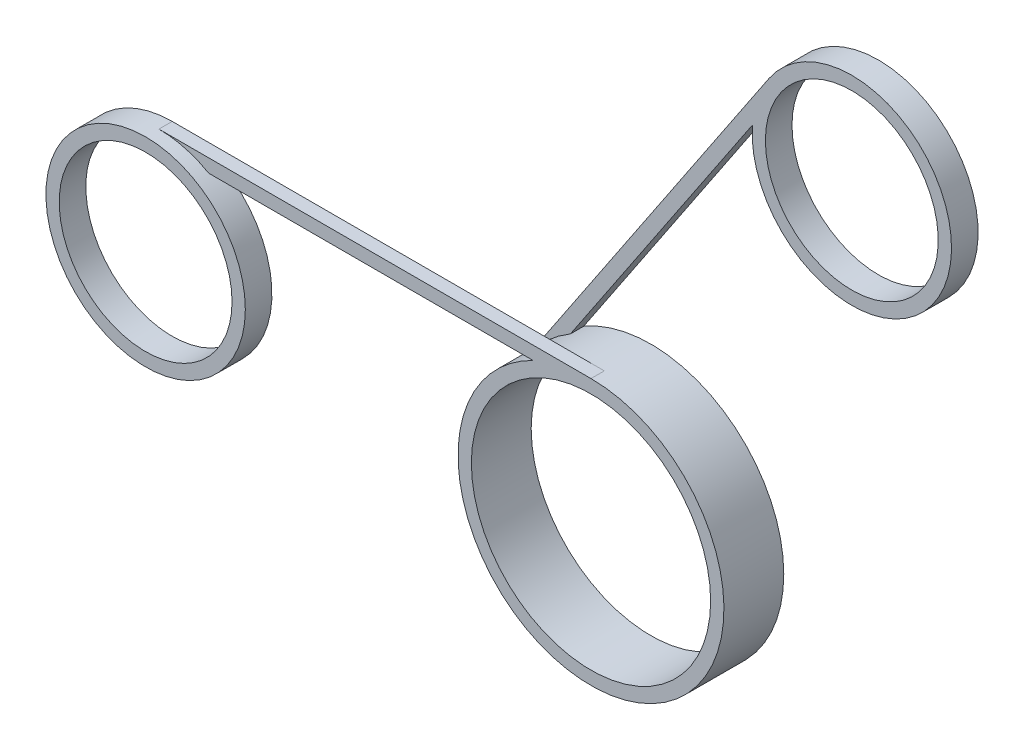
from build123d import *

# Parameters (mm, degrees)
SKETCH1_R           = 10
BOSS_EXTRUDE1_DEPTH = 4.5
SKETCH2_R           = 9
CUT_EXTRUDE1_DEPTH  = 4.5
SKETCH3_W           = 32.5
SKETCH3_H           = 1
BOSS_EXTRUDE2_DEPTH = 1
SKETCH5_R           = 7.5
BOSS_EXTRUDE3_DEPTH = 1
SKETCH6_R           = 6.5
CUT_EXTRUDE2_DEPTH  = 2
BOSS_EXTRUDE4_DEPTH = 1
SKETCH9_R           = 7.5
BOSS_EXTRUDE5_DEPTH = 1
SKETCH10_R          = 6.5
CUT_EXTRUDE3_DEPTH  = 2


with BuildPart() as part:
    # Sketch1 → Boss-Extrude1 (new body)
    with BuildSketch(Plane.XY):
        Circle(SKETCH1_R)
    extrude(amount=BOSS_EXTRUDE1_DEPTH)

    # Sketch2 → Cut-Extrude1 (cut)
    with BuildSketch(Plane.XY.offset(4.5)):
        Circle(SKETCH2_R)
    extrude(amount=-CUT_EXTRUDE1_DEPTH, mode=Mode.SUBTRACT)

    # Sketch3 → Boss-Extrude2 (add)
    with BuildSketch(Plane.XY.offset(4.5)):
        with Locations((-16.25, 9.5)):
            Rectangle(SKETCH3_W, SKETCH3_H)
    extrude(amount=-BOSS_EXTRUDE2_DEPTH)

    # Sketch5 → Boss-Extrude3 (add, symmetric)
    with BuildSketch(Plane.XY.offset(4.5)):
        with Locations((-32.5, 2.5)):
            Circle(SKETCH5_R)
    extrude(amount=BOSS_EXTRUDE3_DEPTH, both=True)

    # Sketch6 → Cut-Extrude2 (cut)
    with BuildSketch(Plane.XY.offset(5.5)):
        with Locations((-32.5, 2.5)):
            Circle(SKETCH6_R)
    extrude(amount=-CUT_EXTRUDE2_DEPTH, mode=Mode.SUBTRACT)

    # Sketch8 → Boss-Extrude4 (add)
    with BuildSketch(Plane(origin=(0, 0, 0), x_dir=(-1, 0, 0), z_dir=(0, 0, -1))):
        Polygon((8.194096935, 5.732082992), (-9.885510569, 32.739078243), (-10.716495038, 32.182782628), (7.362918515, 5.175657537), align=None)
    extrude(amount=-BOSS_EXTRUDE4_DEPTH)

    # Sketch9 → Boss-Extrude5 (add, symmetric)
    with BuildSketch(Plane(origin=(0, 0, 0), x_dir=(-1, 0, 0), z_dir=(0, 0, -1))):
        with Locations((-16.117894088, 28.566861127)):
            Circle(SKETCH9_R)
    extrude(amount=BOSS_EXTRUDE5_DEPTH, both=True)

    # Sketch10 → Cut-Extrude3 (cut)
    with BuildSketch(Plane(origin=(0, 0, -1), x_dir=(-1, 0, 0), z_dir=(0, 0, -1))):
        with Locations((-16.117894088, 28.566861127)):
            Circle(SKETCH10_R)
    extrude(amount=-CUT_EXTRUDE3_DEPTH, mode=Mode.SUBTRACT)


solid = part.part
